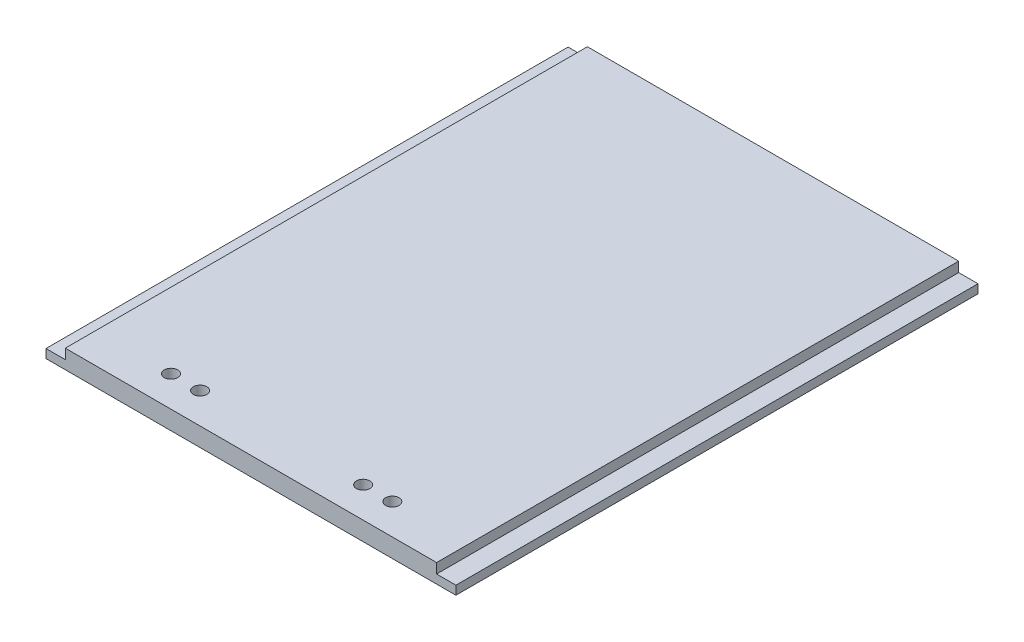
from build123d import *

# Parameters (mm, degrees)
SKETCH1_W           = 139.192
SKETCH1_H           = 177.292
BOSS_EXTRUDE1_DEPTH = 6.35
SKETCH2_W           = 6.55
SKETCH2_H           = 177.292
CUT_EXTRUDE1_DEPTH  = 3.375
SKETCH5_R           = 2.286
CUT_EXTRUDE3_DEPTH  = 12.7


with BuildPart() as part:
    # Sketch1 → Boss-Extrude1 (new body)
    with BuildSketch(Plane(origin=(0, 0, 0), x_dir=(1, 0, 0), z_dir=(0, 1, 0))):
        with Locations((69.596, 88.646)):
            Rectangle(SKETCH1_W, SKETCH1_H)
    extrude(amount=BOSS_EXTRUDE1_DEPTH)

    # Sketch2 → Cut-Extrude1 (cut)
    with BuildSketch(Plane(origin=(0, 6.35, 0), x_dir=(1, 0, 0), z_dir=(0, 1, 0))):
        with Locations((135.917, 88.646)):
            Rectangle(SKETCH2_W, SKETCH2_H)
        with Locations((3.275, 88.646)):
            Rectangle(SKETCH2_W, SKETCH2_H)
    extrude(amount=-CUT_EXTRUDE1_DEPTH, mode=Mode.SUBTRACT)

    # Sketch5 → Cut-Extrude3 (cut)
    with BuildSketch(Plane.XZ):
        with Locations((107.188, -10.414)):
            Circle(SKETCH5_R)
        with Locations((97.282, -10.414)):
            Circle(SKETCH5_R)
        with Locations((41.91, -10.414)):
            Circle(SKETCH5_R)
        with Locations((32.004, -10.414)):
            Circle(SKETCH5_R)
    extrude(amount=-CUT_EXTRUDE3_DEPTH, mode=Mode.SUBTRACT)


solid = part.part
